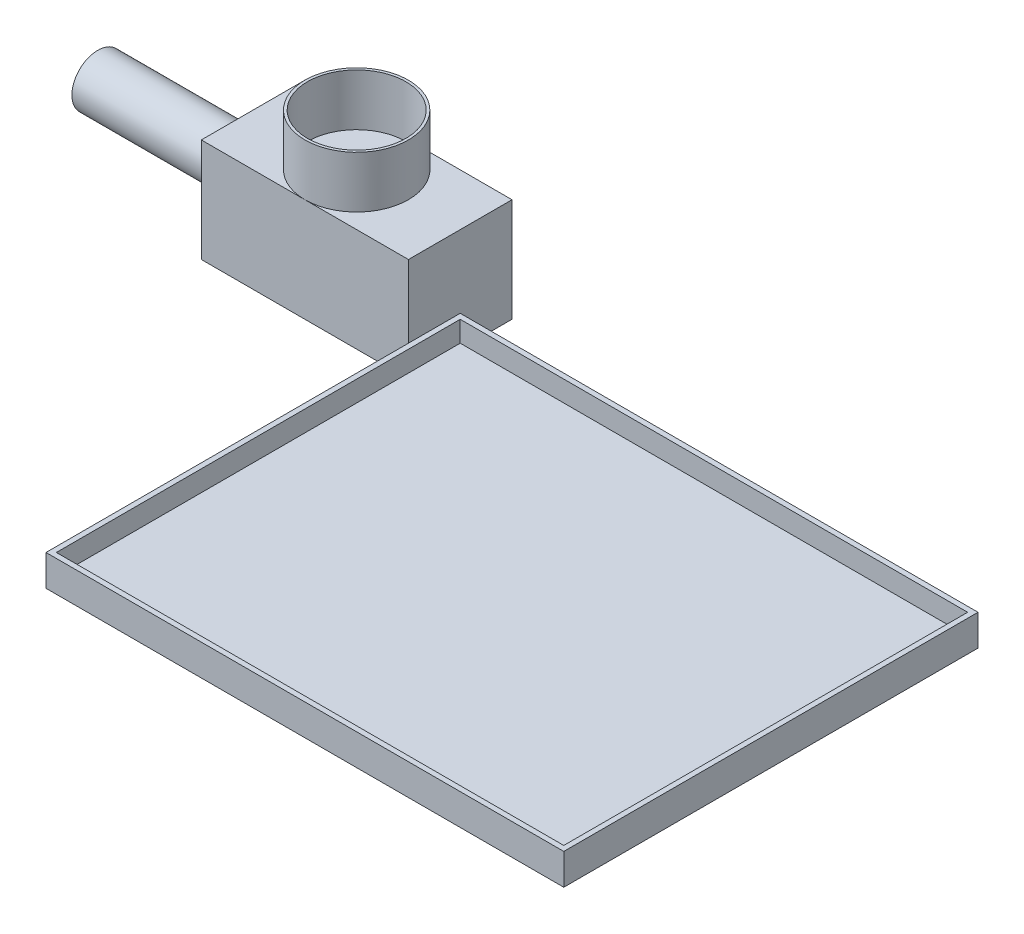
from build123d import *

# Parameters (mm, degrees)
SKETCH1_R           = 25
BOSS_EXTRUDE1_DEPTH = 150
SKETCH2_W           = 100
SKETCH2_H           = 100
BOSS_EXTRUDE2_DEPTH = 200
SKETCH3_R           = 50
SKETCH3_R_2         = 47.5
BOSS_EXTRUDE3_DEPTH = 50
SKETCH4_W           = 500
SKETCH4_H           = 400
SKETCH4_W_2         = 490
SKETCH4_H_2         = 390
BOSS_EXTRUDE4_DEPTH = 30
SKETCH5_W           = 490
SKETCH5_H           = 390
BOSS_EXTRUDE5_DEPTH = 10


with BuildPart() as part:
    # Sketch1 → Boss-Extrude1 (new body)
    with BuildSketch(Plane(origin=(0, 0, 0), x_dir=(0, 0, -1), z_dir=(1, 0, 0))):
        Circle(SKETCH1_R)
    extrude(amount=BOSS_EXTRUDE1_DEPTH)

    # Sketch2 → Boss-Extrude2 (add)
    with BuildSketch(Plane(origin=(150, 0, 0), x_dir=(0, 0, -1), z_dir=(1, 0, 0))):
        Rectangle(SKETCH2_W, SKETCH2_H)
    extrude(amount=BOSS_EXTRUDE2_DEPTH)

    # Sketch3 → Boss-Extrude3 (add)
    with BuildSketch(Plane(origin=(0, 50, 0), x_dir=(1, 0, 0), z_dir=(0, 1, 0))):
        with Locations((250, 0)):
            Circle(SKETCH3_R)
        with Locations((250, 0)):
            Circle(SKETCH3_R_2, mode=Mode.SUBTRACT)
    extrude(amount=BOSS_EXTRUDE3_DEPTH)

    # Sketch4 → Boss-Extrude4 (add)
    with BuildSketch(Plane(origin=(0, -50, 0), x_dir=(1, 0, 0), z_dir=(0, 1, 0))):
        with Locations((600, -200)):
            Rectangle(SKETCH4_W, SKETCH4_H)
        with Locations((600, -200)):
            Rectangle(SKETCH4_W_2, SKETCH4_H_2, mode=Mode.SUBTRACT)
    extrude(amount=BOSS_EXTRUDE4_DEPTH)

    # Sketch5 → Boss-Extrude5 (add)
    with BuildSketch(Plane.XZ.offset(50)):
        with Locations((600, 200)):
            Rectangle(SKETCH5_W, SKETCH5_H)
    extrude(amount=-BOSS_EXTRUDE5_DEPTH)


solid = part.part
